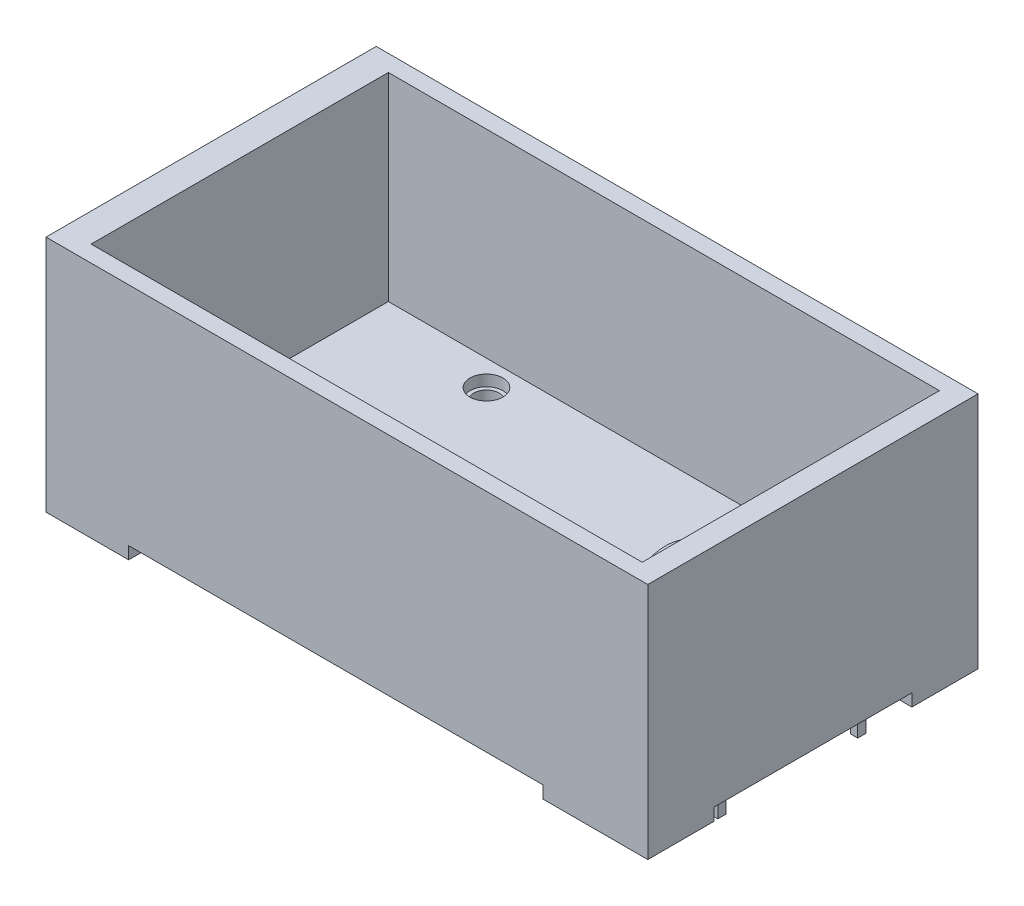
from build123d import *

# Parameters (mm, degrees)
SKETCH_1_W          = 54.61
SKETCH_1_H          = 29.97
EXTRUDE_1_DEPTH     = 2.5
EXTRUDE_2_DEPTH     = 17
CUT_EXTRUDE_1_DEPTH = 30.97
SKETCH_4_R          = 1.145
CUT_EXTRUDE_2_DEPTH = 3.5
SKETCH_5_R          = 2.25
SKETCH_5_W          = 7.5
SKETCH_5_H          = 6
SKETCH_5_W_2        = 9.5
EXTRUDE_3_DEPTH     = 1.12
SKETCH_6_R          = 1.145
CUT_EXTRUDE_3_DEPTH = 4.62
SKETCH_7_R          = 1.5
CUT_EXTRUDE_4_DEPTH = 1
SKETCH_9_W          = 0.66
SKETCH_9_H          = 0.76
EXTRUDE_5_DEPTH     = 3
SKETCH_10_R         = 3.75
EXTRUDE_6_DEPTH     = 1
SKETCH_11_R         = 3
SKETCH_11_R_2       = 2
EXTRUDE_7_DEPTH     = 4
SKETCH_12_R         = 4.25
SKETCH_12_R_2       = 3.25
EXTRUDE_8_DEPTH     = 4
SKETCH5_W           = 26
SKETCH5_H           = 4
CUT_EXTRUDE4_DEPTH  = 17
BOSS_EXTRUDE1_DEPTH = 18
SKETCH7_W           = 2
SKETCH7_H           = 29.97
BOSS_EXTRUDE2_DEPTH = 1


with BuildPart() as part:
    # Эскиз1 → Бобышка-Вытянуть1 (new body)
    with BuildSketch(Plane(origin=(0, 0, 0), x_dir=(1, 0, 0), z_dir=(0, 1, 0))):
        Rectangle(SKETCH_1_W, SKETCH_1_H)
    extrude(amount=EXTRUDE_1_DEPTH)

    # Эскиз2 → Бобышка-Вытянуть2 (add)
    with BuildSketch(Plane(origin=(0, 2.5, 0), x_dir=(1, 0, 0), z_dir=(0, 1, 0))):
        with BuildLine():
            Line((27.305, -14.985), (-0.695, -14.985))
            Line((-0.695, -14.985), (-0.695, -13.485))
            Line((-0.695, -13.485), (23.305, -13.485))
            ThreePointArc((23.305, -13.485), (24.719213562, -12.899213562), (25.305, -11.485))
            Line((25.305, -11.485), (25.305, 11.485))
            ThreePointArc((25.305, 11.485), (24.719213562, 12.899213562), (23.305, 13.485))
            Line((23.305, 13.485), (-0.695, 13.485))
            Line((-0.695, 13.485), (-0.695, 14.985))
            Line((-0.695, 14.985), (27.305, 14.985))
            Line((27.305, 14.985), (27.305, -14.985))
        make_face()
    extrude(amount=EXTRUDE_2_DEPTH)

    # Эскиз3 → Вырез-Вытянуть1 (cut, through all)
    with BuildSketch(Plane.XY.offset(14.985)):
        Polygon((-0.695, 2.5), (25.305, 19.5), (-0.695, 19.5), align=None)
    extrude(amount=-CUT_EXTRUDE_1_DEPTH, mode=Mode.SUBTRACT)

    # Эскиз4 → Вырез-Вытянуть2 (cut, through all)
    with BuildSketch(Plane(origin=(0, 2.5, 0), x_dir=(1, 0, 0), z_dir=(0, 1, 0))):
        with Locations((-13.495, 11.175)):
            Circle(SKETCH_4_R)
        with Locations((-0.005, -11.175)):
            Circle(SKETCH_4_R)
        with Locations((13.475, 11.175)):
            Circle(SKETCH_4_R)
    extrude(amount=-CUT_EXTRUDE_2_DEPTH, mode=Mode.SUBTRACT)

    # Эскиз5 → Бобышка-Вытянуть3 (add)
    with BuildSketch(Plane.XZ):
        with Locations((-0.005, 11.175)):
            Circle(SKETCH_5_R)
        with Locations((13.475, -11.175)):
            Circle(SKETCH_5_R)
        with Locations((-13.495, -11.175)):
            Circle(SKETCH_5_R)
        with Locations((-23.555, 11.985)):
            Rectangle(SKETCH_5_W, SKETCH_5_H)
        with Locations((22.555, 11.985)):
            Rectangle(SKETCH_5_W_2, SKETCH_5_H)
        with Locations((22.555, -11.985)):
            Rectangle(SKETCH_5_W_2, SKETCH_5_H)
        with Locations((-23.555, -11.985)):
            Rectangle(SKETCH_5_W, SKETCH_5_H)
    extrude(amount=EXTRUDE_3_DEPTH)

    # Эскиз6 → Вырез-Вытянуть3 (cut, through all)
    with BuildSketch(Plane(origin=(0, 2.5, 0), x_dir=(1, 0, 0), z_dir=(0, 1, 0))):
        with Locations((-13.495, 11.175)):
            Circle(SKETCH_6_R)
        with Locations((13.475, 11.175)):
            Circle(SKETCH_6_R)
        with Locations((-0.005, -11.175)):
            Circle(SKETCH_6_R)
    extrude(amount=-CUT_EXTRUDE_3_DEPTH, mode=Mode.SUBTRACT)

    # Эскиз7 → Вырез-Вытянуть4 (cut)
    with BuildSketch(Plane(origin=(0, 2.5, 0), x_dir=(1, 0, 0), z_dir=(0, 1, 0))):
        with Locations((-13.495, 11.175)):
            Circle(SKETCH_7_R)
        with Locations((13.475, 11.175)):
            Circle(SKETCH_7_R)
        with Locations((-0.005, -11.175)):
            Circle(SKETCH_7_R)
    extrude(amount=-CUT_EXTRUDE_4_DEPTH, mode=Mode.SUBTRACT)

    # Эскиз9 → Бобышка-Вытянуть5 (add)
    with BuildSketch(Plane.XZ):
        with Locations((25.075, 6.35)):
            Rectangle(SKETCH_9_W, SKETCH_9_H)
        with Locations((25.075, -6.35)):
            Rectangle(SKETCH_9_W, SKETCH_9_H)
    extrude(amount=EXTRUDE_5_DEPTH)

    # Эскиз10 → Бобышка-Вытянуть6 (add)
    with BuildSketch(Plane.ZY.offset(-25.305)):
        with Locations((-6.35, 11.48)):
            Circle(SKETCH_10_R)
        with Locations((6.35, 11.48)):
            Circle(SKETCH_10_R)
    extrude(amount=EXTRUDE_6_DEPTH)

    # Эскиз11 → Бобышка-Вытянуть7 (add)
    with BuildSketch(Plane.ZY.offset(-24.305)):
        with Locations((-6.35, 11.48)):
            Circle(SKETCH_11_R)
        with Locations((-6.35, 11.48)):
            Circle(SKETCH_11_R_2, mode=Mode.SUBTRACT)
    extrude(amount=EXTRUDE_7_DEPTH)

    # Эскиз12 → Бобышка-Вытянуть8 (add)
    with BuildSketch(Plane.ZY.offset(-24.305)):
        with Locations((6.35, 11.48)):
            Circle(SKETCH_12_R)
        with Locations((6.35, 11.48)):
            Circle(SKETCH_12_R_2, mode=Mode.SUBTRACT)
    extrude(amount=EXTRUDE_8_DEPTH)

    # Sketch5 → Cut-Extrude4 (cut)
    with BuildSketch(Plane(origin=(0, 19.5, 0), x_dir=(1, 0, 0), z_dir=(0, 1, 0))):
        with Locations((12.305, -12.985)):
            Rectangle(SKETCH5_W, SKETCH5_H)
        with Locations((12.305, 12.985)):
            Rectangle(SKETCH5_W, SKETCH5_H)
    extrude(amount=-CUT_EXTRUDE4_DEPTH, mode=Mode.SUBTRACT)

    # Sketch6 → Boss-Extrude1 (add)
    with BuildSketch(Plane(origin=(0, 2.5, 0), x_dir=(1, 0, 0), z_dir=(0, 1, 0))):
        Polygon((25.305, 13.485), (25.305, 14.985), (-27.305, 14.985), (-27.305, -14.985), (25.305, -14.985), (25.305, -13.485), (-24.705, -13.485), (-24.705, 13.485), align=None)
    extrude(amount=BOSS_EXTRUDE1_DEPTH)

    # Sketch7 → Boss-Extrude2 (add)
    with BuildSketch(Plane(origin=(0, 19.5, 0), x_dir=(1, 0, 0), z_dir=(0, 1, 0))):
        with Locations((26.305, 0)):
            Rectangle(SKETCH7_W, SKETCH7_H)
    extrude(amount=BOSS_EXTRUDE2_DEPTH)


solid = part.part
